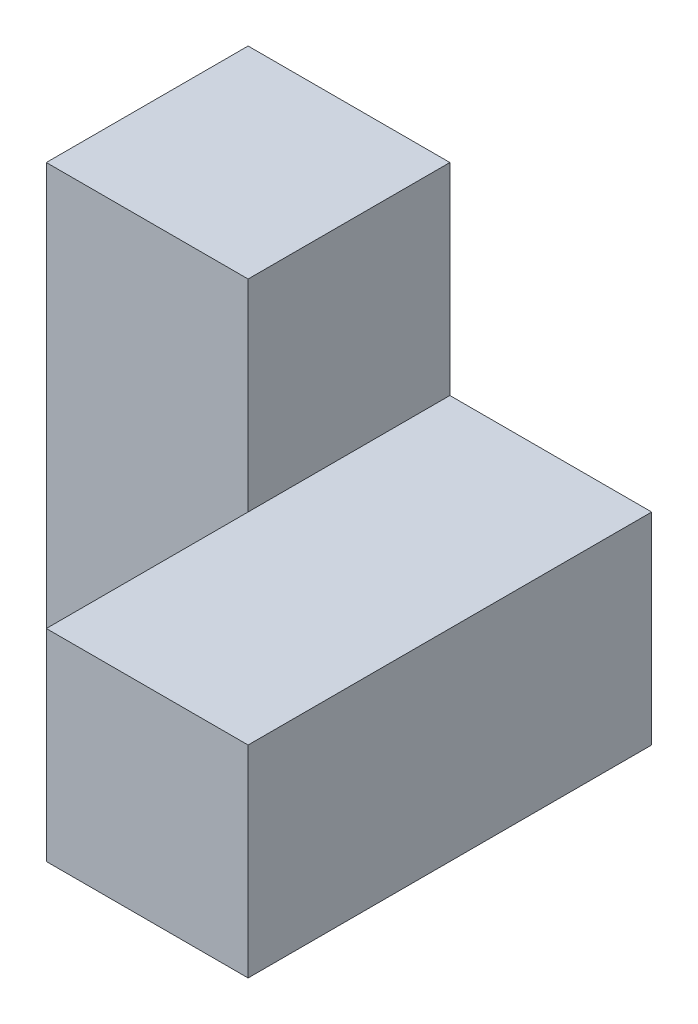
from build123d import *

# Parameters (mm, degrees)
SKETCH1_W           = 50.8
SKETCH1_H           = 50.8
BOSS_EXTRUDE1_DEPTH = 25.4
SKETCH2_W           = 25.4
SKETCH2_H           = 25.4
CUT_EXTRUDE1_DEPTH  = 26.4
SKETCH3_W           = 25.4
SKETCH3_H           = 25.4
BOSS_EXTRUDE2_DEPTH = 25.4


with BuildPart() as part:
    # Sketch1 → Boss-Extrude1 (new body)
    with BuildSketch(Plane(origin=(0, 0, 0), x_dir=(1, 0, 0), z_dir=(0, 1, 0))):
        Rectangle(SKETCH1_W, SKETCH1_H)
    extrude(amount=BOSS_EXTRUDE1_DEPTH)

    # Sketch2 → Cut-Extrude1 (cut, through all)
    with BuildSketch(Plane(origin=(0, 25.4, 0), x_dir=(1, 0, 0), z_dir=(0, 1, 0))):
        with Locations((-12.7, -12.7)):
            Rectangle(SKETCH2_W, SKETCH2_H)
    extrude(amount=-CUT_EXTRUDE1_DEPTH, mode=Mode.SUBTRACT)

    # Sketch3 → Boss-Extrude2 (add)
    with BuildSketch(Plane(origin=(0, 25.4, 0), x_dir=(1, 0, 0), z_dir=(0, 1, 0))):
        with Locations((-12.7, 12.7)):
            Rectangle(SKETCH3_W, SKETCH3_H)
    extrude(amount=BOSS_EXTRUDE2_DEPTH)


solid = part.part
